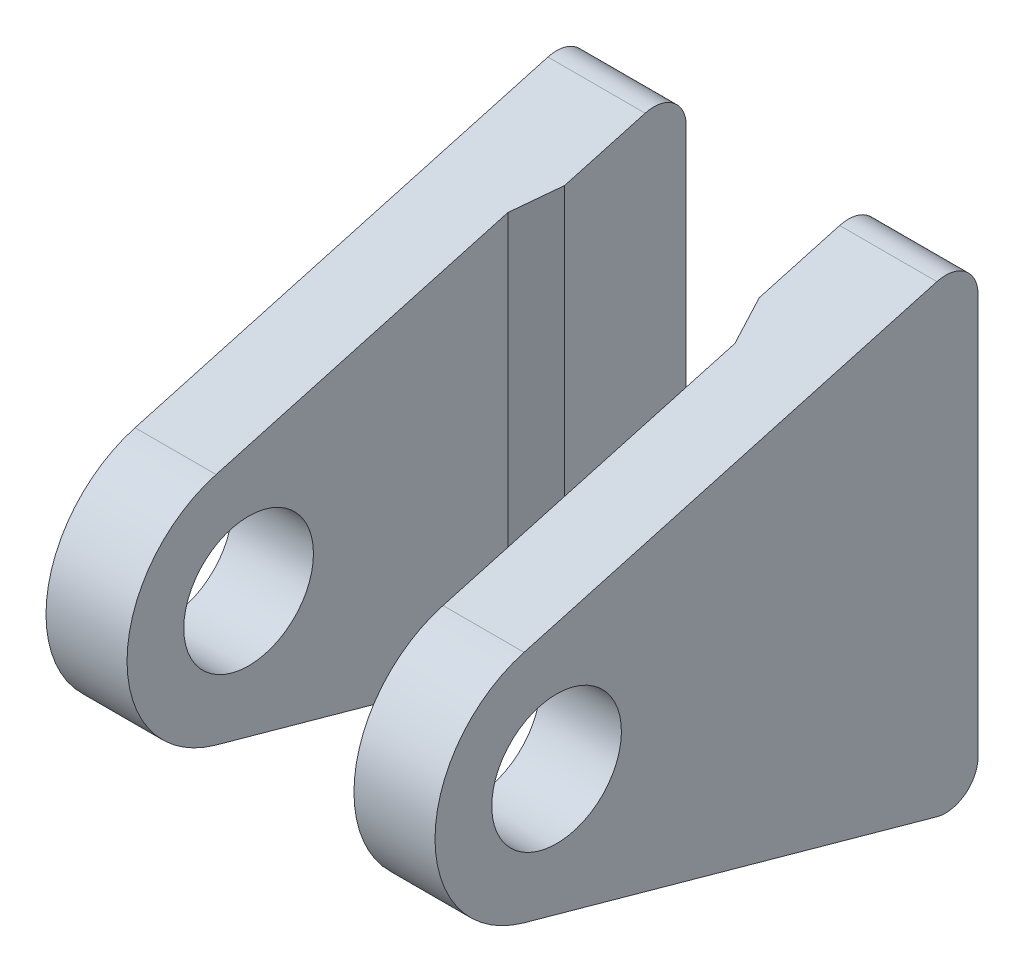
from build123d import *

# Parameters (mm, degrees)
SKETCH_1_W             = 24
SKETCH_1_H             = 30
EXTRUDE_1_DEPTH        = 4
EXTRUDE_2_DEPTH        = 5
EXTRUDE_START          = -24
EXTRUDE_3_DEPTH        = 5
HOLE_WIZARD_M6_1_D     = 5
HOLE_WIZARD_M6_1_DEPTH = 5
SKETCH_13_R            = 4
CUT_EXTRUDE_1_DEPTH    = 25
CHAMFER_1_SIZE         = 4
CHAMFER_1_SIZE2        = 10
CHAMFER_2_SIZE         = 10
CHAMFER_2_SIZE2        = 4
HOLE_WIZARD_M5_1_D     = 4.2
HOLE_WIZARD_M5_1_DEPTH = 10
HOLE_WIZARD_M5_1_TIP   = 1.2618073
SKETCH_15_W            = 12
SKETCH_15_H            = 30
CUT_EXTRUDE_2_DEPTH    = 38.5
SKETCH_16_W            = 24
SKETCH_16_H            = 30
CUT_EXTRUDE_3_DEPTH    = 4
FILLET_1_R             = 2
FILLET_2_R             = 2


with BuildPart() as part:
    # 草图1 → 凸台-拉伸1 (new body)
    with BuildSketch(Plane.XY):
        Rectangle(SKETCH_1_W, SKETCH_1_H)
    extrude(amount=EXTRUDE_1_DEPTH)

    # 草图4 → 凸台-拉伸2 (add)
    with BuildSketch(Plane.ZY.offset(12)):
        with BuildLine():
            Line((4, 15), (32.005844192, 7.226796599))
            ThreePointArc((32.005844192, 7.226796599), (37.5, 0), (32.005844192, -7.226796599))
            Line((32.005844192, -7.226796599), (4, -15))
            Line((4, -15), (4, 15))
        make_face()
    extrude(amount=-EXTRUDE_2_DEPTH)

    # 草图4<2> → 凸台-拉伸3 (add)
    with BuildSketch(Plane.ZY.offset(12).offset(EXTRUDE_START)):
        with BuildLine():
            Line((4, 15), (32.005844192, 7.226796599))
            ThreePointArc((32.005844192, 7.226796599), (37.5, 0), (32.005844192, -7.226796599))
            Line((32.005844192, -7.226796599), (4, -15))
            Line((4, -15), (4, 15))
        make_face()
    extrude(amount=EXTRUDE_3_DEPTH)

    # M6 螺纹孔1
    with Locations(Plane(origin=(-12, 0, 30), x_dir=(0, -1, 0), z_dir=(-1, 0, 0))):
        with Locations((0, 0)):
            Hole(HOLE_WIZARD_M6_1_D / 2, depth=HOLE_WIZARD_M6_1_DEPTH)

    # 草图13 → 切除-拉伸1 (cut, through all)
    with BuildSketch(Plane(origin=(12, 0, 0), x_dir=(0, 0, -1), z_dir=(1, 0, 0))):
        with Locations((-30, 0)):
            Circle(SKETCH_13_R)
    extrude(amount=-CUT_EXTRUDE_1_DEPTH, mode=Mode.SUBTRACT)

    # 倒角1
    chamfer_1_edges = [part.edges().sort_by_distance(p)[0] for p in [
        (7, 0, 4),
    ]]
    chamfer_1_side = [part.faces().sort_by_distance(p)[0] for p in [
        (0, 0, 4),
    ]]
    chamfer(chamfer_1_edges, length=CHAMFER_1_SIZE, length2=CHAMFER_1_SIZE2, reference=chamfer_1_side[0])

    # 倒角2
    chamfer_2_edges = [part.edges().sort_by_distance(p)[0] for p in [
        (-7, 0, 4),
    ]]
    chamfer_2_side = [part.faces().sort_by_distance(p)[0] for p in [
        (-7, 0, 16.950170632),
    ]]
    chamfer(chamfer_2_edges, length=CHAMFER_2_SIZE, length2=CHAMFER_2_SIZE2, reference=chamfer_2_side[0])

    # M5 螺纹孔1
    with Locations(Plane(origin=(0, 0, 0), x_dir=(-1, 0, 0), z_dir=(0, 0, -1))):
        with Locations((-9, 8), (9, 8), (9, -8), (-9, -8)):
            Hole(HOLE_WIZARD_M5_1_D / 2, depth=HOLE_WIZARD_M5_1_DEPTH)
            with Locations((0, 0, -(HOLE_WIZARD_M5_1_DEPTH + HOLE_WIZARD_M5_1_TIP / 2))):  # 118° drill point
                Cone(0, HOLE_WIZARD_M5_1_D / 2, HOLE_WIZARD_M5_1_TIP, mode=Mode.SUBTRACT)

    # 草图15 → 切除-拉伸2 (cut, through all)
    with BuildSketch(Plane(origin=(0, 0, 0), x_dir=(-1, 0, 0), z_dir=(0, 0, -1))):
        Rectangle(SKETCH_15_W, SKETCH_15_H)
    extrude(amount=-CUT_EXTRUDE_2_DEPTH, mode=Mode.SUBTRACT)

    # 草图16 → 切除-拉伸3 (cut)
    with BuildSketch(Plane(origin=(0, 0, 0), x_dir=(-1, 0, 0), z_dir=(0, 0, -1))):
        Rectangle(SKETCH_16_W, SKETCH_16_H)
    extrude(amount=-CUT_EXTRUDE_3_DEPTH, mode=Mode.SUBTRACT)

    # 圆角1
    fillet_1_edges = [part.edges().sort_by_distance(p)[0] for p in [
        (-9, 15, 4),
        (-9, -15, 4),
    ]]
    fillet(fillet_1_edges, radius=FILLET_1_R)

    # 圆角2
    fillet_2_edges = [part.edges().sort_by_distance(p)[0] for p in [
        (9, -15, 4),
        (9, 15, 4),
    ]]
    fillet(fillet_2_edges, radius=FILLET_2_R)


solid = part.part
